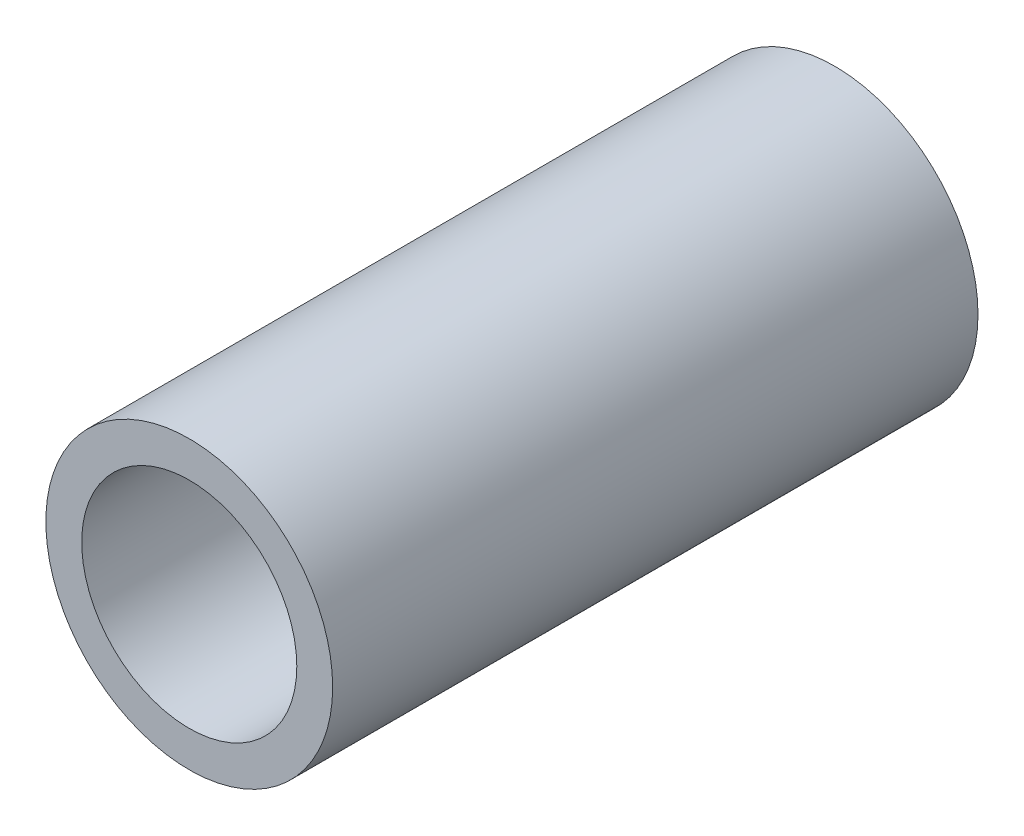
from build123d import *

# Parameters (mm, degrees)
SKETCH_1_R      = 2
SKETCH_1_R_2    = 1.5
EXTRUDE_1_DEPTH = 9


with BuildPart() as part:
    # 草图1 → 凸台-拉伸1 (new body)
    with BuildSketch(Plane.XY):
        Circle(SKETCH_1_R)
        Circle(SKETCH_1_R_2, mode=Mode.SUBTRACT)
    extrude(amount=EXTRUDE_1_DEPTH)


solid = part.part
